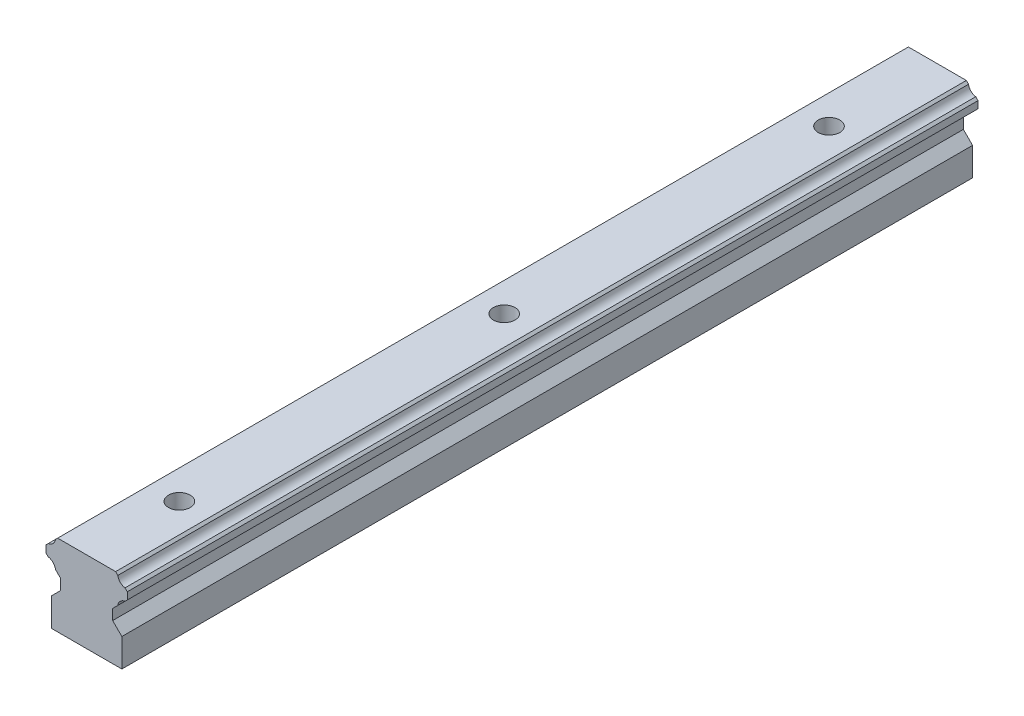
from build123d import *

# Parameters (mm, degrees)
BOSS_EXTRUDE1_DEPTH = 156.99994
SKETCH2_R           = 2
CUT_EXTRUDE1_DEPTH  = 16


with BuildPart() as part:
    # Sketch1 → Boss-Extrude1 (new body)
    with BuildSketch(Plane.XY):
        with BuildLine():
            Line((-6.5, 0), (6.5, 0))
            Line((6.5, 0), (6.5, 5.2))
            Line((6.5, 5.2), (4.8, 6.9))
            Line((4.8, 6.9), (4.8, 8.84))
            Line((4.8, 8.84), (5.754868434, 9.794868434))
            ThreePointArc((5.754868434, 9.794868434), (6.196913421, 10.683086579), (7.085131566, 11.125131566))
            Line((7.085131566, 11.125131566), (7.5, 11.54))
            Line((7.5, 11.54), (7.5, 12.85))
            Line((7.5, 12.85), (7.08164233, 13.26835767))
            ThreePointArc((7.08164233, 13.26835767), (6.196913421, 13.709913421), (5.75535767, 14.59464233))
            Line((5.75535767, 14.59464233), (5.35, 15))
            Line((5.35, 15), (-5.35, 15))
            Line((-5.35, 15), (-5.75535767, 14.59464233))
            ThreePointArc((-5.75535767, 14.59464233), (-6.196913421, 13.709913421), (-7.08164233, 13.26835767))
            Line((-7.08164233, 13.26835767), (-7.5, 12.85))
            Line((-7.5, 12.85), (-7.5, 11.54))
            Line((-7.5, 11.54), (-7.085131566, 11.125131566))
            ThreePointArc((-7.085131566, 11.125131566), (-6.196913421, 10.683086579), (-5.754868434, 9.794868434))
            Line((-5.754868434, 9.794868434), (-4.8, 8.84))
            Line((-4.8, 8.84), (-4.8, 6.9))
            Line((-4.8, 6.9), (-6.5, 5.2))
            Line((-6.5, 5.2), (-6.5, 0))
        make_face()
    extrude(amount=BOSS_EXTRUDE1_DEPTH)

    # Sketch2 → Cut-Extrude1 (cut, through all)
    with BuildSketch(Plane(origin=(0, 15, 0), x_dir=(1, 0, 0), z_dir=(0, 1, 0))):
        with Locations((0, -20)):
            Circle(SKETCH2_R)
        with Locations((0, -79.944)):
            Circle(SKETCH2_R)
        with Locations((0, -139.888)):
            Circle(SKETCH2_R)
    extrude(amount=-CUT_EXTRUDE1_DEPTH, mode=Mode.SUBTRACT)


solid = part.part
